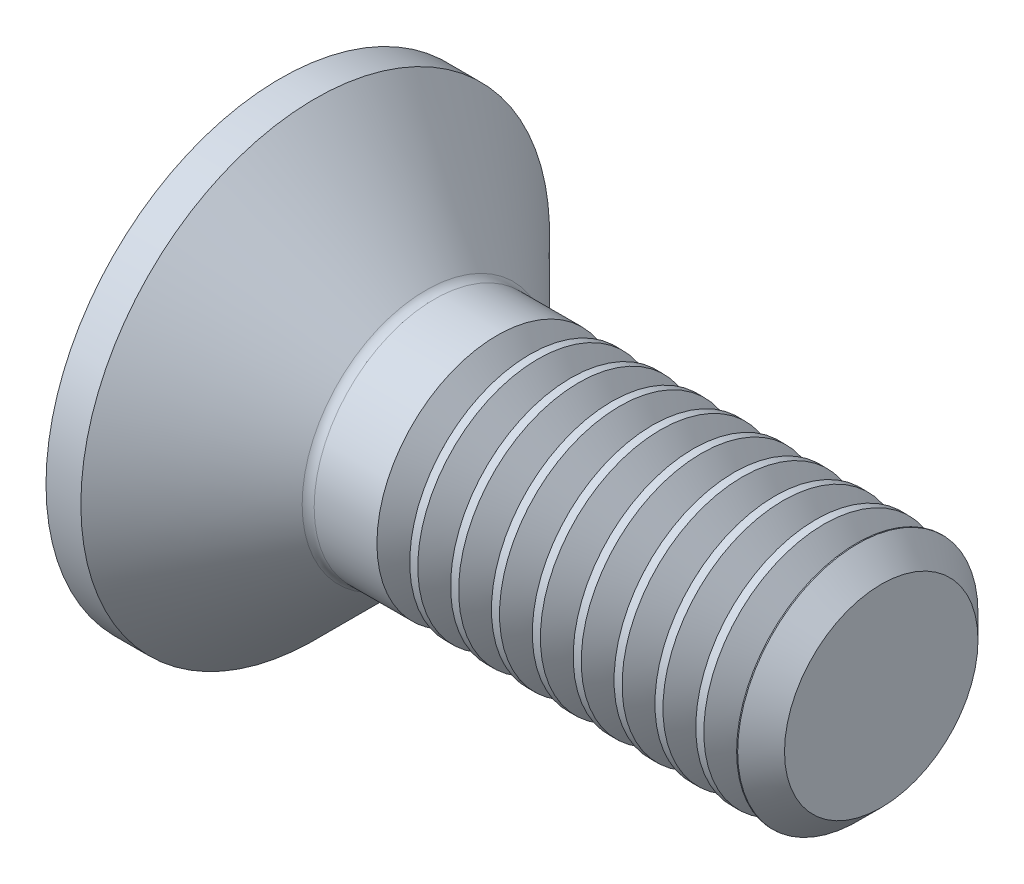
from build123d import *

# Parameters (mm, degrees)
FILLET1_R       = 0.2
HEX_2_DEPTH     = 1.5
THDSCHPAT_COUNT = 9
THDSCHPAT_PITCH = 0.68


with BuildPart() as part:
    # BodySke → BaseBody (revolve)
    with BuildSketch(Plane.XY):
        Polygon((0, 0), (0, 3.9), (0.58, 3.9), (2.48, 2), (9.61, 2), (10, 1.61), (10, 0), align=None)
    revolve(axis=Axis((0, 0, 0), (1, 0, 0)))

    # Fillet1
    fillet1_edges = [part.edges().sort_by_distance(p)[0] for p in [
        (2.48, -2, 0),
    ]]
    fillet(fillet1_edges, radius=FILLET1_R)

    # Sketch2 → PreBroach (revolve, cut)
    with BuildSketch(Plane.XY):
        Polygon((0, 1.25), (1.5, 1.25), (2.221687836, 0), (0, 0), align=None)
    revolve(axis=Axis((0, 0, 0), (1, 0, 0)), mode=Mode.SUBTRACT)

    # Sketch3 → Hex 2 (cut)
    with BuildSketch(Plane.ZY):
        Polygon((-1.25, -0.721687836), (-1.25, 0.721687836), (0, 1.443375673), (1.25, 0.721687836), (1.25, -0.721687836), (0, -1.443375673), align=None)
    extrude(amount=-HEX_2_DEPTH, mode=Mode.SUBTRACT)

    # ThdSchSke → ThreadSchematic (revolve, cut)
    with BuildSketch(Plane.XY):
        Polygon((3.880001, -1.61), (3.60692006, -2), (3.60692006, -2.5), (4.15308194, -2.5), (4.15308194, -2), align=None)
    threadschematic = revolve(axis=Axis((-3.175, 0, 0), (1, 0, 0)), mode=Mode.SUBTRACT)

    # ThdSchPat: ThreadSchematic ×9
    with Locations(*[(i * THDSCHPAT_PITCH, 0, 0) for i in range(1, THDSCHPAT_COUNT)]):
        add(threadschematic, mode=Mode.SUBTRACT)


solid = part.part
